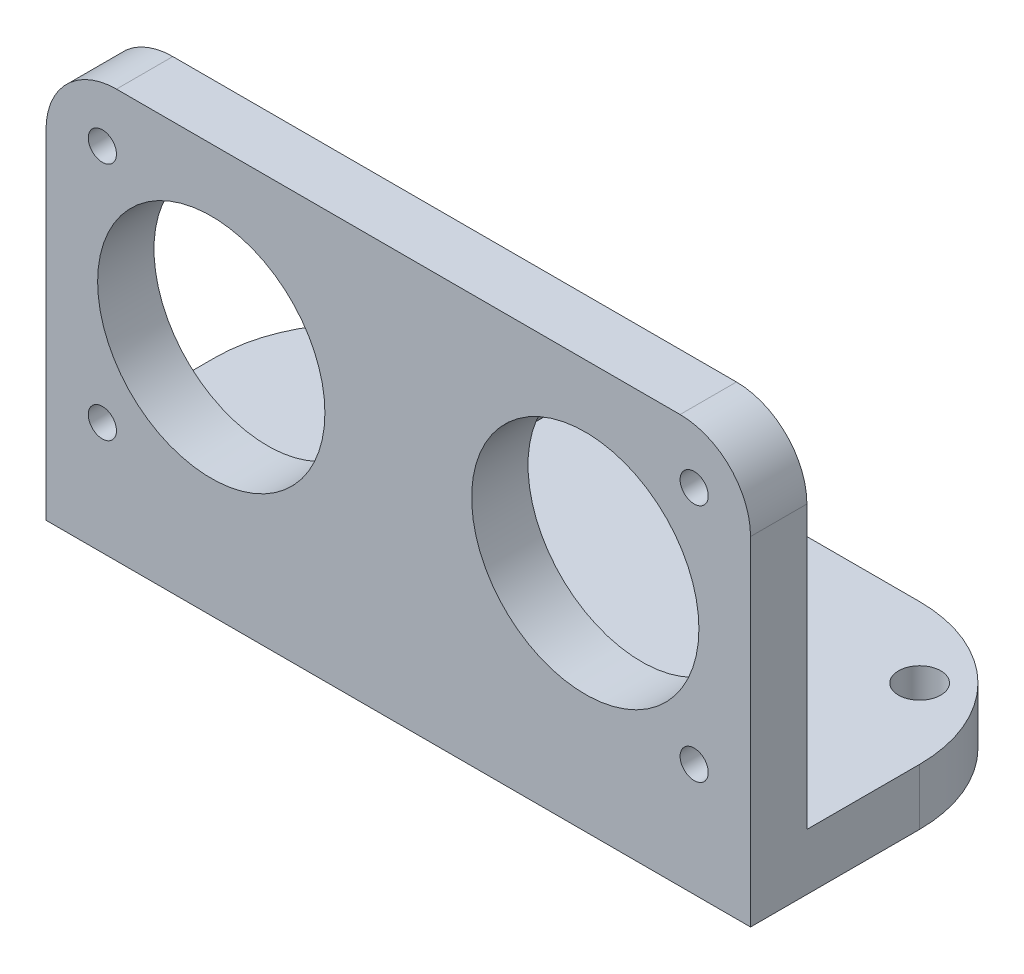
from build123d import *

# Parameters (mm, degrees)
SKETCH1_W             = 50
SKETCH1_H             = 25
BOSS_EXTRUDE1_DEPTH   = 4
SKETCH2_W             = 50
SKETCH2_H             = 22
BOSS_EXTRUDE2_DEPTH   = 4
SKETCH3_R             = 8.0645
CUT_EXTRUDE1_DEPTH    = 23
SKETCH4_R             = 2
BOSS_EXTRUDE4_DEPTH   = 5
F_3_0MM_DOWEL_HOLE1_D = 3
F_2_0MM_DOWEL_HOLE1_D = 2
MIRROR4_COPY_1_D      = 2
FILLET1_R             = 10
FILLET2_R             = 5


with BuildPart() as part:
    # Sketch1 → Boss-Extrude1 (new body)
    with BuildSketch(Plane.XY):
        Rectangle(SKETCH1_W, SKETCH1_H)
    extrude(amount=BOSS_EXTRUDE1_DEPTH)

    # Sketch2 → Boss-Extrude2 (add)
    with BuildSketch(Plane.XZ.offset(12.5)):
        with Locations((0, -7)):
            Rectangle(SKETCH2_W, SKETCH2_H)
    extrude(amount=BOSS_EXTRUDE2_DEPTH)

    # Sketch3 → Cut-Extrude1 (cut, through all)
    with BuildSketch(Plane.XY.offset(4)):
        with Locations((13.2715, 0)):
            Circle(SKETCH3_R)
    cut_extrude1 = extrude(amount=-CUT_EXTRUDE1_DEPTH, mode=Mode.SUBTRACT)

    # Mirror1: Cut-Extrude1 across plane
    add(cut_extrude1.mirror(Plane(origin=(0, 0, 0), x_dir=(0, 0, 1), z_dir=(1, 0, 0))), mode=Mode.SUBTRACT)

    # Sketch4 → Boss-Extrude4 (add)
    with BuildSketch(Plane(origin=(0, 0, 0), x_dir=(-1, 0, 0), z_dir=(0, 0, -1))):
        Circle(SKETCH4_R)
    extrude(amount=BOSS_EXTRUDE4_DEPTH)

    # Ø3.0mm Dowel Hole1 (through all)
    with Locations(Plane(origin=(0, -12.5, 0), x_dir=(1, 0, 0), z_dir=(0, 1, 0))):
        with Locations((-20, 13)):
            f_3_0mm_dowel_hole1 = Hole(F_3_0MM_DOWEL_HOLE1_D / 2)

    # Mirror2: Ø3.0mm Dowel Hole1 across plane
    add(f_3_0mm_dowel_hole1.mirror(Plane(origin=(0, 0, 0), x_dir=(0, 0, 1), z_dir=(1, 0, 0))), mode=Mode.SUBTRACT)

    # Ø2.0mm Dowel Hole1 (through all)
    with Locations(Plane(origin=(0, 0, 0), x_dir=(-1, 0, 0), z_dir=(0, 0, -1))):
        with Locations((-21, 8.5)):
            f_2_0mm_dowel_hole1 = Hole(F_2_0MM_DOWEL_HOLE1_D / 2)

    # Mirror3: Ø2.0mm Dowel Hole1 across plane
    add(f_2_0mm_dowel_hole1.mirror(Plane.ZX), mode=Mode.SUBTRACT)

    # Mirror4: Ø2.0mm Dowel Hole1 across plane
    add(f_2_0mm_dowel_hole1.mirror(Plane(origin=(0, 0, 0), x_dir=(0, 0, 1), z_dir=(1, 0, 0))), mode=Mode.SUBTRACT)

    # Mirror4 copy 1 (through all)
    with Locations(Plane(origin=(0, 0, 0), x_dir=(1, 0, 0), z_dir=(0, 0, -1))):
        with Locations((-21, 8.5)):
            Hole(MIRROR4_COPY_1_D / 2)

    # Fillet1
    fillet1_edges = [part.edges().sort_by_distance(p)[0] for p in [
        (-25, -14.5, -18),
        (25, -14.5, -18),
    ]]
    fillet(fillet1_edges, radius=FILLET1_R)

    # Fillet2
    fillet2_edges = [part.edges().sort_by_distance(p)[0] for p in [
        (-25, 12.5, 2),
        (25, 12.5, 2),
    ]]
    fillet(fillet2_edges, radius=FILLET2_R)


solid = part.part
